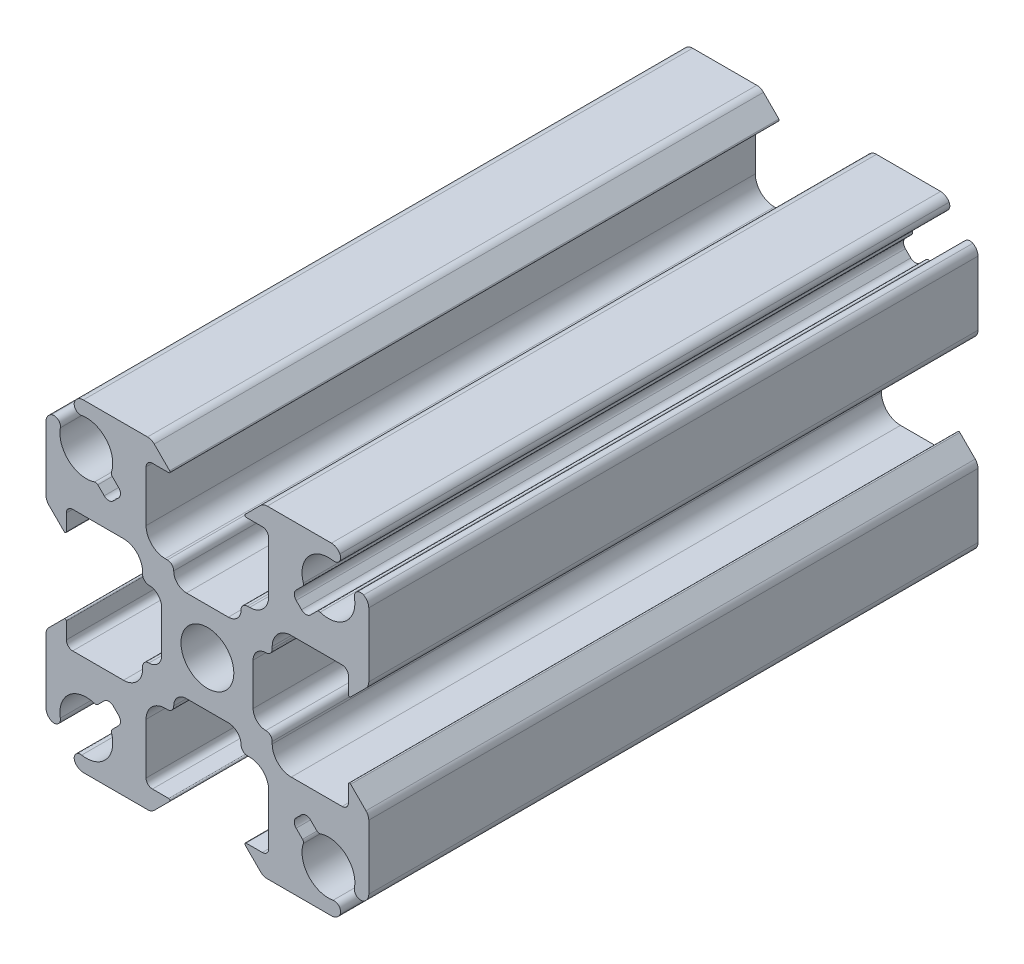
from build123d import *

# Parameters (mm, degrees)
SKETCH1_R           = 2.08
BOSS_EXTRUDE1_DEPTH = 23.970292928


with BuildPart() as part:
    # Sketch1 → Boss-Extrude1 (new body, symmetric)
    with BuildSketch(Plane(origin=(0, 0, 0), x_dir=(-1, 0, 0), z_dir=(0, 0, -1))):
        with BuildLine():
            Line((-7.48853247, 8.61990332), (-6.985643798, 8.117014648))
            ThreePointArc((-6.985643798, 8.117014648), (-6.839197188, 7.763461257), (-6.985643798, 7.409907866))
            Line((-6.985643798, 7.409907866), (-7.409907866, 6.985643798))
            ThreePointArc((-7.409907866, 6.985643798), (-7.763461257, 6.839197188), (-8.117014648, 6.985643798))
            Line((-8.117014648, 6.985643798), (-8.61990332, 7.48853247))
            ThreePointArc((-8.61990332, 7.48853247), (-8.738774884, 7.554957329), (-8.874825936, 7.549228331))
            ThreePointArc((-8.874825936, 7.549228331), (-10.889377278, 7.955008076), (-11.572136222, 9.893284252))
            ThreePointArc((-11.572136222, 9.893284252), (-11.766795458, 10.383720777), (-12.292708824, 10.42656157))
            ThreePointArc((-12.292708824, 10.42656157), (-12.590129525, 10.150252615), (-12.7, 9.759440396))
            Line((-12.7, 9.759440396), (-12.7, 4.710660172))
            ThreePointArc((-12.7, 4.710660172), (-12.642909649, 4.423647598), (-12.480330086, 4.180330086))
            Line((-12.480330086, 4.180330086), (-11.270710678, 2.970710678))
            ThreePointArc((-11.270710678, 2.970710678), (-11.161731657, 2.949033403), (-11.1, 3.041421356))
            Line((-11.1, 3.041421356), (-11.1, 4.325))
            ThreePointArc((-11.1, 4.325), (-10.953553391, 4.678553391), (-10.6, 4.825))
            Line((-10.6, 4.825), (-6.6, 4.825))
            ThreePointArc((-6.6, 4.825), (-5.539339828, 4.385660172), (-5.1, 3.325))
            Line((-5.1, 3.325), (-5.1, 3.15))
            ThreePointArc((-5.1, 3.15), (-4.953553391, 2.796446609), (-4.6, 2.65))
            ThreePointArc((-4.6, 2.65), (-3.892893219, 2.357106781), (-3.6, 1.65))
            Line((-3.6, 1.65), (-3.6, -1.65))
            ThreePointArc((-3.6, -1.65), (-3.892893219, -2.357106781), (-4.6, -2.65))
            ThreePointArc((-4.6, -2.65), (-4.953553391, -2.796446609), (-5.1, -3.15))
            Line((-5.1, -3.15), (-5.1, -3.325))
            ThreePointArc((-5.1, -3.325), (-5.539339828, -4.385660172), (-6.6, -4.825))
            Line((-6.6, -4.825), (-10.6, -4.825))
            ThreePointArc((-10.6, -4.825), (-10.953553391, -4.678553391), (-11.1, -4.325))
            Line((-11.1, -4.325), (-11.1, -3.041421356))
            ThreePointArc((-11.1, -3.041421356), (-11.161731657, -2.949033403), (-11.270710678, -2.970710678))
            Line((-11.270710678, -2.970710678), (-12.480330086, -4.180330086))
            ThreePointArc((-12.480330086, -4.180330086), (-12.642909649, -4.423647598), (-12.7, -4.710660172))
            Line((-12.7, -4.710660172), (-12.7, -9.759440396))
            ThreePointArc((-12.7, -9.759440396), (-12.590129525, -10.150252615), (-12.292708824, -10.42656157))
            ThreePointArc((-12.292708824, -10.42656157), (-11.766795458, -10.383720777), (-11.572136222, -9.893284252))
            ThreePointArc((-11.572136222, -9.893284252), (-10.889377278, -7.955008076), (-8.874825936, -7.549228331))
            ThreePointArc((-8.874825936, -7.549228331), (-8.738774884, -7.554957329), (-8.61990332, -7.48853247))
            Line((-8.61990332, -7.48853247), (-8.117014648, -6.985643798))
            ThreePointArc((-8.117014648, -6.985643798), (-7.763461257, -6.839197188), (-7.409907866, -6.985643798))
            Line((-7.409907866, -6.985643798), (-6.985643798, -7.409907866))
            ThreePointArc((-6.985643798, -7.409907866), (-6.839197188, -7.763461257), (-6.985643798, -8.117014648))
            Line((-6.985643798, -8.117014648), (-7.48853247, -8.61990332))
            ThreePointArc((-7.48853247, -8.61990332), (-7.554957329, -8.738774884), (-7.549228331, -8.874825936))
            ThreePointArc((-7.549228331, -8.874825936), (-7.955008076, -10.889377278), (-9.893284252, -11.572136222))
            ThreePointArc((-9.893284252, -11.572136222), (-10.383720777, -11.766795458), (-10.42656157, -12.292708824))
            ThreePointArc((-10.42656157, -12.292708824), (-10.150252615, -12.590129525), (-9.759440396, -12.7))
            Line((-9.759440396, -12.7), (-4.710660172, -12.7))
            ThreePointArc((-4.710660172, -12.7), (-4.423647598, -12.642909649), (-4.180330086, -12.480330086))
            Line((-4.180330086, -12.480330086), (-2.970710678, -11.270710678))
            ThreePointArc((-2.970710678, -11.270710678), (-2.949033403, -11.161731657), (-3.041421356, -11.1))
            Line((-3.041421356, -11.1), (-4.325, -11.1))
            ThreePointArc((-4.325, -11.1), (-4.678553391, -10.953553391), (-4.825, -10.6))
            Line((-4.825, -10.6), (-4.825, -6.6))
            ThreePointArc((-4.825, -6.6), (-4.385660172, -5.539339828), (-3.325, -5.1))
            Line((-3.325, -5.1), (-3.15, -5.1))
            ThreePointArc((-3.15, -5.1), (-2.796446609, -4.953553391), (-2.65, -4.6))
            ThreePointArc((-2.65, -4.6), (-2.357106781, -3.892893219), (-1.65, -3.6))
            Line((-1.65, -3.6), (1.65, -3.6))
            ThreePointArc((1.65, -3.6), (2.357106781, -3.892893219), (2.65, -4.6))
            ThreePointArc((2.65, -4.6), (2.796446609, -4.953553391), (3.15, -5.1))
            Line((3.15, -5.1), (3.325, -5.1))
            ThreePointArc((3.325, -5.1), (4.385660172, -5.539339828), (4.825, -6.6))
            Line((4.825, -6.6), (4.825, -10.6))
            ThreePointArc((4.825, -10.6), (4.678553391, -10.953553391), (4.325, -11.1))
            Line((4.325, -11.1), (3.041421356, -11.1))
            ThreePointArc((3.041421356, -11.1), (2.949033403, -11.161731657), (2.970710678, -11.270710678))
            Line((2.970710678, -11.270710678), (4.180330086, -12.480330086))
            ThreePointArc((4.180330086, -12.480330086), (4.423647598, -12.642909649), (4.710660172, -12.7))
            Line((4.710660172, -12.7), (9.759440396, -12.7))
            ThreePointArc((9.759440396, -12.7), (10.150252615, -12.590129525), (10.42656157, -12.292708824))
            ThreePointArc((10.42656157, -12.292708824), (10.383720777, -11.766795458), (9.893284252, -11.572136222))
            ThreePointArc((9.893284252, -11.572136222), (7.955008076, -10.889377278), (7.549228331, -8.874825936))
            ThreePointArc((7.549228331, -8.874825936), (7.554957329, -8.738774884), (7.48853247, -8.61990332))
            Line((7.48853247, -8.61990332), (6.985643798, -8.117014648))
            ThreePointArc((6.985643798, -8.117014648), (6.839197188, -7.763461257), (6.985643798, -7.409907866))
            Line((6.985643798, -7.409907866), (7.409907866, -6.985643798))
            ThreePointArc((7.409907866, -6.985643798), (7.763461257, -6.839197188), (8.117014648, -6.985643798))
            Line((8.117014648, -6.985643798), (8.61990332, -7.48853247))
            ThreePointArc((8.61990332, -7.48853247), (8.738774884, -7.554957329), (8.874825936, -7.549228331))
            ThreePointArc((8.874825936, -7.549228331), (10.889377278, -7.955008076), (11.572136222, -9.893284252))
            ThreePointArc((11.572136222, -9.893284252), (11.766795458, -10.383720777), (12.292708824, -10.42656157))
            ThreePointArc((12.292708824, -10.42656157), (12.590129525, -10.150252615), (12.7, -9.759440396))
            Line((12.7, -9.759440396), (12.7, -4.710660172))
            ThreePointArc((12.7, -4.710660172), (12.642909649, -4.423647598), (12.480330086, -4.180330086))
            Line((12.480330086, -4.180330086), (11.270710678, -2.970710678))
            ThreePointArc((11.270710678, -2.970710678), (11.161731657, -2.949033403), (11.1, -3.041421356))
            Line((11.1, -3.041421356), (11.1, -4.325))
            ThreePointArc((11.1, -4.325), (10.953553391, -4.678553391), (10.6, -4.825))
            Line((10.6, -4.825), (6.6, -4.825))
            ThreePointArc((6.6, -4.825), (5.539339828, -4.385660172), (5.1, -3.325))
            Line((5.1, -3.325), (5.1, -3.15))
            ThreePointArc((5.1, -3.15), (4.953553391, -2.796446609), (4.6, -2.65))
            ThreePointArc((4.6, -2.65), (3.892893219, -2.357106781), (3.6, -1.65))
            Line((3.6, -1.65), (3.6, 1.65))
            ThreePointArc((3.6, 1.65), (3.892893219, 2.357106781), (4.6, 2.65))
            ThreePointArc((4.6, 2.65), (4.953553391, 2.796446609), (5.1, 3.15))
            Line((5.1, 3.15), (5.1, 3.325))
            ThreePointArc((5.1, 3.325), (5.539339828, 4.385660172), (6.6, 4.825))
            Line((6.6, 4.825), (10.6, 4.825))
            ThreePointArc((10.6, 4.825), (10.953553391, 4.678553391), (11.1, 4.325))
            Line((11.1, 4.325), (11.1, 3.041421356))
            ThreePointArc((11.1, 3.041421356), (11.161731657, 2.949033403), (11.270710678, 2.970710678))
            Line((11.270710678, 2.970710678), (12.480330086, 4.180330086))
            ThreePointArc((12.480330086, 4.180330086), (12.642909649, 4.423647598), (12.7, 4.710660172))
            Line((12.7, 4.710660172), (12.7, 9.759440396))
            ThreePointArc((12.7, 9.759440396), (12.590129525, 10.150252615), (12.292708824, 10.42656157))
            ThreePointArc((12.292708824, 10.42656157), (11.766795458, 10.383720777), (11.572136222, 9.893284252))
            ThreePointArc((11.572136222, 9.893284252), (10.889377278, 7.955008076), (8.874825936, 7.549228331))
            ThreePointArc((8.874825936, 7.549228331), (8.738774884, 7.554957329), (8.61990332, 7.48853247))
            Line((8.61990332, 7.48853247), (8.117014648, 6.985643798))
            ThreePointArc((8.117014648, 6.985643798), (7.763461257, 6.839197188), (7.409907866, 6.985643798))
            Line((7.409907866, 6.985643798), (6.985643798, 7.409907866))
            ThreePointArc((6.985643798, 7.409907866), (6.839197188, 7.763461257), (6.985643798, 8.117014648))
            Line((6.985643798, 8.117014648), (7.48853247, 8.61990332))
            ThreePointArc((7.48853247, 8.61990332), (7.554957329, 8.738774884), (7.549228331, 8.874825936))
            ThreePointArc((7.549228331, 8.874825936), (7.955008076, 10.889377278), (9.893284252, 11.572136222))
            ThreePointArc((9.893284252, 11.572136222), (10.383720777, 11.766795458), (10.42656157, 12.292708824))
            ThreePointArc((10.42656157, 12.292708824), (10.150252615, 12.590129525), (9.759440396, 12.7))
            Line((9.759440396, 12.7), (4.710660172, 12.7))
            ThreePointArc((4.710660172, 12.7), (4.423647598, 12.642909649), (4.180330086, 12.480330086))
            Line((4.180330086, 12.480330086), (2.970710678, 11.270710678))
            ThreePointArc((2.970710678, 11.270710678), (2.949033403, 11.161731657), (3.041421356, 11.1))
            Line((3.041421356, 11.1), (4.325, 11.1))
            ThreePointArc((4.325, 11.1), (4.678553391, 10.953553391), (4.825, 10.6))
            Line((4.825, 10.6), (4.825, 6.6))
            ThreePointArc((4.825, 6.6), (4.385660172, 5.539339828), (3.325, 5.1))
            Line((3.325, 5.1), (3.15, 5.1))
            ThreePointArc((3.15, 5.1), (2.796446609, 4.953553391), (2.65, 4.6))
            ThreePointArc((2.65, 4.6), (2.357106781, 3.892893219), (1.65, 3.6))
            Line((1.65, 3.6), (-1.65, 3.6))
            ThreePointArc((-1.65, 3.6), (-2.357106781, 3.892893219), (-2.65, 4.6))
            ThreePointArc((-2.65, 4.6), (-2.796446609, 4.953553391), (-3.15, 5.1))
            Line((-3.15, 5.1), (-3.325, 5.1))
            ThreePointArc((-3.325, 5.1), (-4.385660172, 5.539339828), (-4.825, 6.6))
            Line((-4.825, 6.6), (-4.825, 10.6))
            ThreePointArc((-4.825, 10.6), (-4.678553391, 10.953553391), (-4.325, 11.1))
            Line((-4.325, 11.1), (-3.041421356, 11.1))
            ThreePointArc((-3.041421356, 11.1), (-2.949033403, 11.161731657), (-2.970710678, 11.270710678))
            Line((-2.970710678, 11.270710678), (-4.180330086, 12.480330086))
            ThreePointArc((-4.180330086, 12.480330086), (-4.423647598, 12.642909649), (-4.710660172, 12.7))
            Line((-4.710660172, 12.7), (-9.759440396, 12.7))
            ThreePointArc((-9.759440396, 12.7), (-10.150252615, 12.590129525), (-10.42656157, 12.292708824))
            ThreePointArc((-10.42656157, 12.292708824), (-10.383720777, 11.766795458), (-9.893284252, 11.572136222))
            ThreePointArc((-9.893284252, 11.572136222), (-7.955008076, 10.889377278), (-7.549228331, 8.874825936))
            ThreePointArc((-7.549228331, 8.874825936), (-7.554957329, 8.738774884), (-7.48853247, 8.61990332))
        make_face()
        Circle(SKETCH1_R, mode=Mode.SUBTRACT)
    extrude(amount=BOSS_EXTRUDE1_DEPTH, both=True)


solid = part.part
